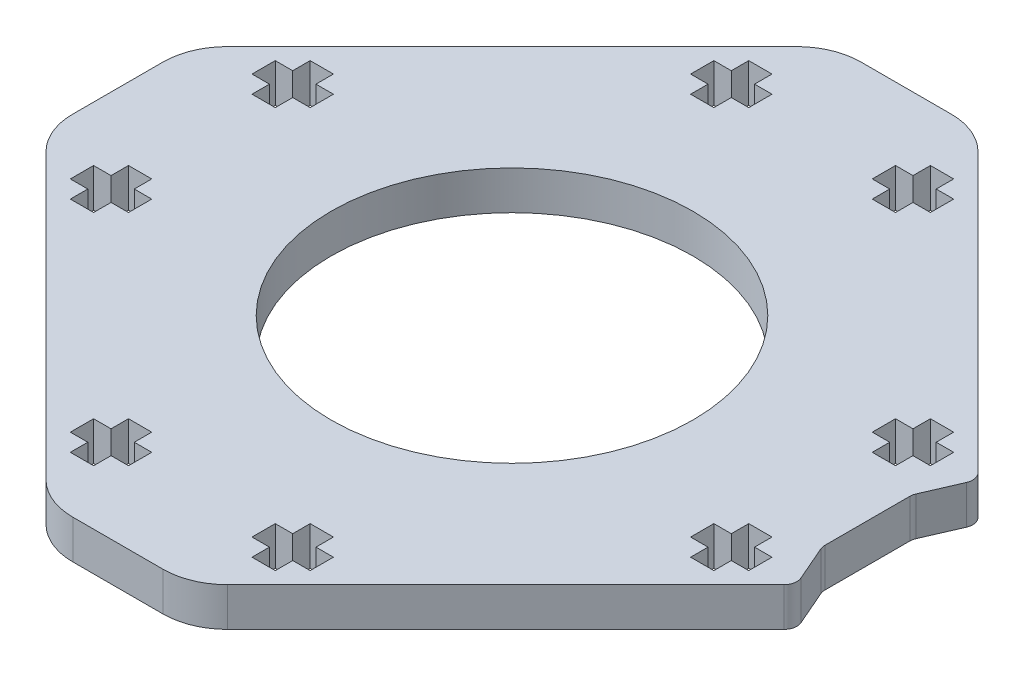
from build123d import *

# Parameters (mm, degrees)
SKETCH1_R           = 14
BOSS_EXTRUDE1_DEPTH = 3
CUT_EXTRUDE1_DEPTH  = 4
FILLET1_R           = 1


with BuildPart() as part:
    # Sketch1 → Boss-Extrude1 (new body)
    with BuildSketch(Plane(origin=(0, 0, 0), x_dir=(1, 0, 0), z_dir=(0, 1, 0))):
        with BuildLine():
            Line((3.491378029, 30.5), (-3.491378029, 30.5))
            ThreePointArc((-3.491378029, 30.5), (-5.40479519, 30.119397663), (-7.026911935, 29.035533906))
            Line((-7.026911935, 29.035533906), (-29.035533906, 7.026911935))
            ThreePointArc((-29.035533906, 7.026911935), (-30.119397663, 5.40479519), (-30.5, 3.491378029))
            Line((-30.5, 3.491378029), (-30.5, -3.491378029))
            ThreePointArc((-30.5, -3.491378029), (-30.119397663, -5.40479519), (-29.035533906, -7.026911935))
            Line((-29.035533906, -7.026911935), (-7.026911935, -29.035533906))
            ThreePointArc((-7.026911935, -29.035533906), (-5.40479519, -30.119397663), (-3.491378029, -30.5))
            Line((-3.491378029, -30.5), (3.491378029, -30.5))
            ThreePointArc((3.491378029, -30.5), (5.40479519, -30.119397663), (7.026911935, -29.035533906))
            Line((7.026911935, -29.035533906), (29.035533906, -7.026911935))
            Line((29.035533906, -7.026911935), (27.5, -3.491378029))
            Line((27.5, -3.491378029), (27.5, 3.491378029))
            Line((27.5, 3.491378029), (29.035533906, 7.026911935))
            Line((29.035533906, 7.026911935), (7.026911935, 29.035533906))
            ThreePointArc((7.026911935, 29.035533906), (5.40479519, 30.119397663), (3.491378029, 30.5))
        make_face()
        Circle(SKETCH1_R, mode=Mode.SUBTRACT)
    extrude(amount=BOSS_EXTRUDE1_DEPTH)

    # Sketch2 → Cut-Extrude1 (cut, through all)
    with BuildSketch(Plane(origin=(0, 3, 0), x_dir=(1, 0, 0), z_dir=(0, 1, 0))):
        Polygon((-26.25, 7.929437252), (-26.25, 6.129437252), (-24.9, 6.129437252), (-24.9, 4.779437252), (-23.1, 4.779437252), (-23.1, 6.129437252), (-21.75, 6.129437252), (-21.75, 7.929437252), (-23.1, 7.929437252), (-23.1, 9.279437252), (-24.9, 9.279437252), (-24.9, 7.929437252), align=None)
        Polygon((-23.1, -4.779437252), (-24.9, -4.779437252), (-24.9, -6.129437252), (-26.25, -6.129437252), (-26.25, -7.929437252), (-24.9, -7.929437252), (-24.9, -9.279437252), (-23.1, -9.279437252), (-23.1, -7.929437252), (-21.75, -7.929437252), (-21.75, -6.129437252), (-23.1, -6.129437252), align=None)
        Polygon((7.929437252, 23.1), (9.279437252, 23.1), (9.279437252, 24.9), (7.929437252, 24.9), (7.929437252, 26.25), (6.129437252, 26.25), (6.129437252, 24.9), (4.779437252, 24.9), (4.779437252, 23.1), (6.129437252, 23.1), (6.129437252, 21.75), (7.929437252, 21.75), align=None)
        Polygon((26.25, -7.929437252), (26.25, -6.129437252), (24.9, -6.129437252), (24.9, -4.779437252), (23.1, -4.779437252), (23.1, -6.129437252), (21.75, -6.129437252), (21.75, -7.929437252), (23.1, -7.929437252), (23.1, -9.279437252), (24.9, -9.279437252), (24.9, -7.929437252), align=None)
        Polygon((-4.779437252, 24.9), (-6.129437252, 24.9), (-6.129437252, 26.25), (-7.929437252, 26.25), (-7.929437252, 24.9), (-9.279437252, 24.9), (-9.279437252, 23.1), (-7.929437252, 23.1), (-7.929437252, 21.75), (-6.129437252, 21.75), (-6.129437252, 23.1), (-4.779437252, 23.1), align=None)
        Polygon((26.25, 7.929437252), (24.9, 7.929437252), (24.9, 9.279437252), (23.1, 9.279437252), (23.1, 7.929437252), (21.75, 7.929437252), (21.75, 6.129437252), (23.1, 6.129437252), (23.1, 4.779437252), (24.9, 4.779437252), (24.9, 6.129437252), (26.25, 6.129437252), align=None)
        Polygon((-6.129437252, -26.25), (-6.129437252, -24.9), (-4.779437252, -24.9), (-4.779437252, -23.1), (-6.129437252, -23.1), (-6.129437252, -21.75), (-7.929437252, -21.75), (-7.929437252, -23.1), (-9.279437252, -23.1), (-9.279437252, -24.9), (-7.929437252, -24.9), (-7.929437252, -26.25), align=None)
        Polygon((7.929437252, -26.25), (7.929437252, -24.9), (9.279437252, -24.9), (9.279437252, -23.1), (7.929437252, -23.1), (7.929437252, -21.75), (6.129437252, -21.75), (6.129437252, -23.1), (4.779437252, -23.1), (4.779437252, -24.9), (6.129437252, -24.9), (6.129437252, -26.25), align=None)
    extrude(amount=-CUT_EXTRUDE1_DEPTH, mode=Mode.SUBTRACT)

    # Fillet1
    fillet1_edges = [part.edges().sort_by_distance(p)[0] for p in [
        (29.035533906, 1.5, -7.026911935),
        (27.5, 1.5, -3.491378029),
        (27.5, 1.5, 3.491378029),
        (29.035533906, 1.5, 7.026911935),
    ]]
    fillet(fillet1_edges, radius=FILLET1_R)


solid = part.part
